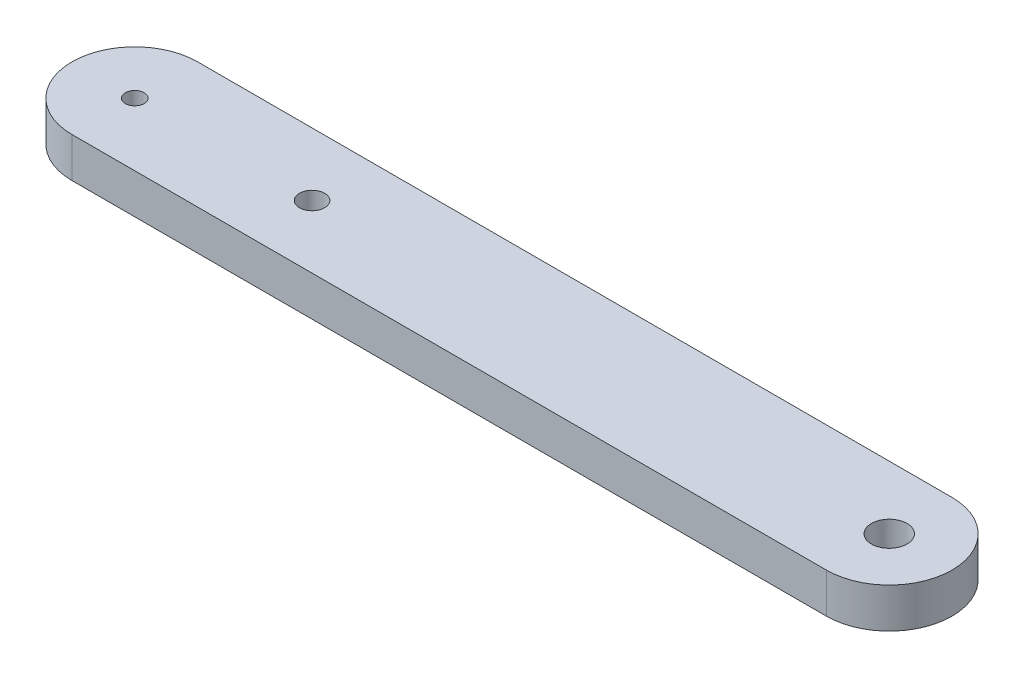
from build123d import *

# Parameters (mm, degrees)
SKETCH3_R          = 1.42
SKETCH3_R_2        = 0.75
ARM_DEPTH          = 3.175
SKETCH5_R          = 1
CUT_EXTRUDE2_DEPTH = 4.175


with BuildPart() as part:
    # Sketch3 → Arm (new body)
    with BuildSketch(Plane(origin=(0, 0, 0), x_dir=(1, 0, 0), z_dir=(0, 1, 0))):
        with BuildLine():
            Line((-30, 5), (30, 5))
            ThreePointArc((30, 5), (35, 0), (30, -5))
            Line((30, -5), (-30, -5))
            ThreePointArc((-30, -5), (-35, 0), (-30, 5))
        make_face()
        with Locations((30, 0)):
            Circle(SKETCH3_R, mode=Mode.SUBTRACT)
        with Locations((-30, 0)):
            Circle(SKETCH3_R_2, mode=Mode.SUBTRACT)
    extrude(amount=ARM_DEPTH)

    # Sketch5 → Cut-Extrude2 (cut, through all)
    with BuildSketch(Plane(origin=(0, 3.175, 0), x_dir=(1, 0, 0), z_dir=(0, 1, 0))):
        with Locations((-15.9, 0)):
            Circle(SKETCH5_R)
    extrude(amount=-CUT_EXTRUDE2_DEPTH, mode=Mode.SUBTRACT)


solid = part.part
